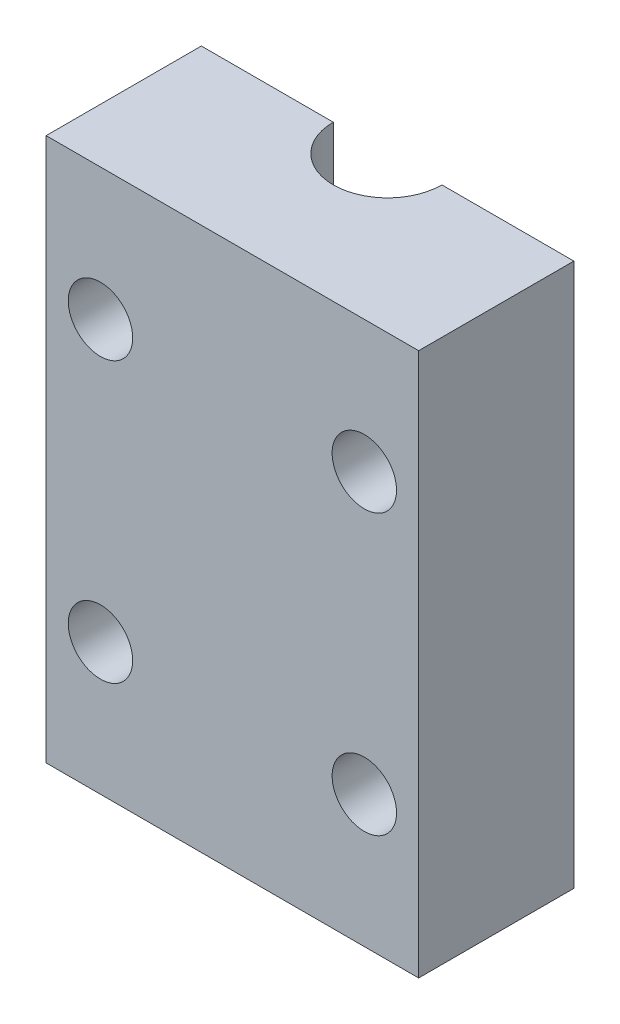
from build123d import *

# Parameters (mm, degrees)
SKETCH1_W               = 48
SKETCH1_H               = 20
BOSS_EXTRUDE1_DEPTH     = 70
SKETCH3_R               = 4.15
CUT_EXTRUDE2_DEPTH      = 21
CUT_EXTRUDE3_DEPTH      = 1
CUT_EXTRUDE3_DEPTH_BACK = 71


with BuildPart() as part:
    # Sketch1 → Boss-Extrude1 (new body)
    with BuildSketch(Plane(origin=(0, 0, 0), x_dir=(1, 0, 0), z_dir=(0, 1, 0))):
        Rectangle(SKETCH1_W, SKETCH1_H)
    extrude(amount=BOSS_EXTRUDE1_DEPTH)

    # Sketch3 → Cut-Extrude2 (cut, through all)
    with BuildSketch(Plane.XY.offset(10)):
        with Locations((17, 53)):
            Circle(SKETCH3_R)
        with Locations((-17, 53)):
            Circle(SKETCH3_R)
        with Locations((-17, 17)):
            Circle(SKETCH3_R)
        with Locations((17, 17)):
            Circle(SKETCH3_R)
    extrude(amount=-CUT_EXTRUDE2_DEPTH, mode=Mode.SUBTRACT)

    # Sketch4 → Cut-Extrude3 (cut, two sides)
    with BuildSketch(Plane(origin=(0, 70, 0), x_dir=(1, 0, 0), z_dir=(0, 1, 0))) as cut_extrude3_sk:
        with BuildLine():
            Line((-7, 93.783466983), (-7, 10))
            ThreePointArc((-7, 10), (0, 3), (7, 10))
            Line((7, 10), (7, 93.783466983))
            Line((7, 93.783466983), (7, 261.350400948))
            Line((7, 261.350400948), (-7, 261.350400948))
            Line((-7, 261.350400948), (-7, 93.783466983))
        make_face()
    extrude(amount=CUT_EXTRUDE3_DEPTH, mode=Mode.SUBTRACT)
    extrude(cut_extrude3_sk.sketch, amount=-CUT_EXTRUDE3_DEPTH_BACK, mode=Mode.SUBTRACT)


solid = part.part
